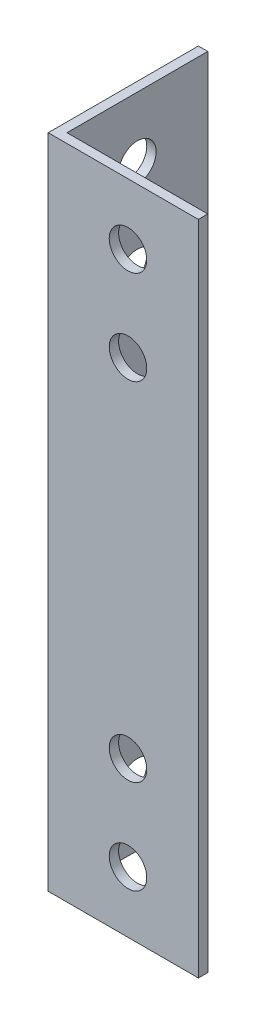
from build123d import *

# Parameters (mm, degrees)
EXTRUSION1_DEPTH = 70
EXTRUSION2_REACH = 3
ESQUISSE2_R      = 2
EXTRUSION3_REACH = 3
ESQUISSE3_R      = 2


with BuildPart() as part:
    # Esquisse1 → Extrusion1 (new body)
    with BuildSketch(Plane(origin=(0, 0, 0), x_dir=(1, 0, 0), z_dir=(0, 1, 0))):
        Polygon((0, 0), (0, 16), (1, 16), (1, 1), (16, 1), (16, 0), align=None)
    extrude(amount=EXTRUSION1_DEPTH)

    # Esquisse2 → Extrusion2 (cut, up to next)
    with BuildSketch(Plane(origin=(1, 0, 0), x_dir=(0, 0, -1), z_dir=(1, 0, 0)), mode=Mode.PRIVATE) as extrusion2_sk1:
        with Locations((8.5, 16.5)):
            Circle(ESQUISSE2_R)
    extrusion2_tool1 = extrude(extrusion2_sk1.sketch, amount=-EXTRUSION2_REACH, mode=Mode.PRIVATE) & part.part
    add(extrusion2_tool1.solids().sort_by_distance((1, 16.5, -8.5))[0], mode=Mode.SUBTRACT)
    # Esquisse2 → Extrusion2 (cut, up to next)
    with BuildSketch(Plane(origin=(1, 0, 0), x_dir=(0, 0, -1), z_dir=(1, 0, 0)), mode=Mode.PRIVATE) as extrusion2_sk2:
        with Locations((8.5, 6.5)):
            Circle(ESQUISSE2_R)
    extrusion2_tool2 = extrude(extrusion2_sk2.sketch, amount=-EXTRUSION2_REACH, mode=Mode.PRIVATE) & part.part
    add(extrusion2_tool2.solids().sort_by_distance((1, 6.5, -8.5))[0], mode=Mode.SUBTRACT)
    # Esquisse2 → Extrusion2 (cut, up to next)
    with BuildSketch(Plane(origin=(1, 0, 0), x_dir=(0, 0, -1), z_dir=(1, 0, 0)), mode=Mode.PRIVATE) as extrusion2_sk3:
        with Locations((8.5, 53.5)):
            Circle(ESQUISSE2_R)
    extrusion2_tool3 = extrude(extrusion2_sk3.sketch, amount=-EXTRUSION2_REACH, mode=Mode.PRIVATE) & part.part
    add(extrusion2_tool3.solids().sort_by_distance((1, 53.5, -8.5))[0], mode=Mode.SUBTRACT)
    # Esquisse2 → Extrusion2 (cut, up to next)
    with BuildSketch(Plane(origin=(1, 0, 0), x_dir=(0, 0, -1), z_dir=(1, 0, 0)), mode=Mode.PRIVATE) as extrusion2_sk4:
        with Locations((8.5, 63.5)):
            Circle(ESQUISSE2_R)
    extrusion2_tool4 = extrude(extrusion2_sk4.sketch, amount=-EXTRUSION2_REACH, mode=Mode.PRIVATE) & part.part
    add(extrusion2_tool4.solids().sort_by_distance((1, 63.5, -8.5))[0], mode=Mode.SUBTRACT)

    # Esquisse3 → Extrusion3 (cut, up to next)
    with BuildSketch(Plane(origin=(0, 0, -1), x_dir=(-1, 0, 0), z_dir=(0, 0, -1)), mode=Mode.PRIVATE) as extrusion3_sk1:
        with Locations((-8.5, 53.5)):
            Circle(ESQUISSE3_R)
    extrusion3_tool1 = extrude(extrusion3_sk1.sketch, amount=-EXTRUSION3_REACH, mode=Mode.PRIVATE) & part.part
    add(extrusion3_tool1.solids().sort_by_distance((8.5, 53.5, -1))[0], mode=Mode.SUBTRACT)
    # Esquisse3 → Extrusion3 (cut, up to next)
    with BuildSketch(Plane(origin=(0, 0, -1), x_dir=(-1, 0, 0), z_dir=(0, 0, -1)), mode=Mode.PRIVATE) as extrusion3_sk2:
        with Locations((-8.5, 63.5)):
            Circle(ESQUISSE3_R)
    extrusion3_tool2 = extrude(extrusion3_sk2.sketch, amount=-EXTRUSION3_REACH, mode=Mode.PRIVATE) & part.part
    add(extrusion3_tool2.solids().sort_by_distance((8.5, 63.5, -1))[0], mode=Mode.SUBTRACT)
    # Esquisse3 → Extrusion3 (cut, up to next)
    with BuildSketch(Plane(origin=(0, 0, -1), x_dir=(-1, 0, 0), z_dir=(0, 0, -1)), mode=Mode.PRIVATE) as extrusion3_sk3:
        with Locations((-8.5, 6.5)):
            Circle(ESQUISSE3_R)
    extrusion3_tool3 = extrude(extrusion3_sk3.sketch, amount=-EXTRUSION3_REACH, mode=Mode.PRIVATE) & part.part
    add(extrusion3_tool3.solids().sort_by_distance((8.5, 6.5, -1))[0], mode=Mode.SUBTRACT)
    # Esquisse3 → Extrusion3 (cut, up to next)
    with BuildSketch(Plane(origin=(0, 0, -1), x_dir=(-1, 0, 0), z_dir=(0, 0, -1)), mode=Mode.PRIVATE) as extrusion3_sk4:
        with Locations((-8.5, 16.5)):
            Circle(ESQUISSE3_R)
    extrusion3_tool4 = extrude(extrusion3_sk4.sketch, amount=-EXTRUSION3_REACH, mode=Mode.PRIVATE) & part.part
    add(extrusion3_tool4.solids().sort_by_distance((8.5, 16.5, -1))[0], mode=Mode.SUBTRACT)


solid = part.part
